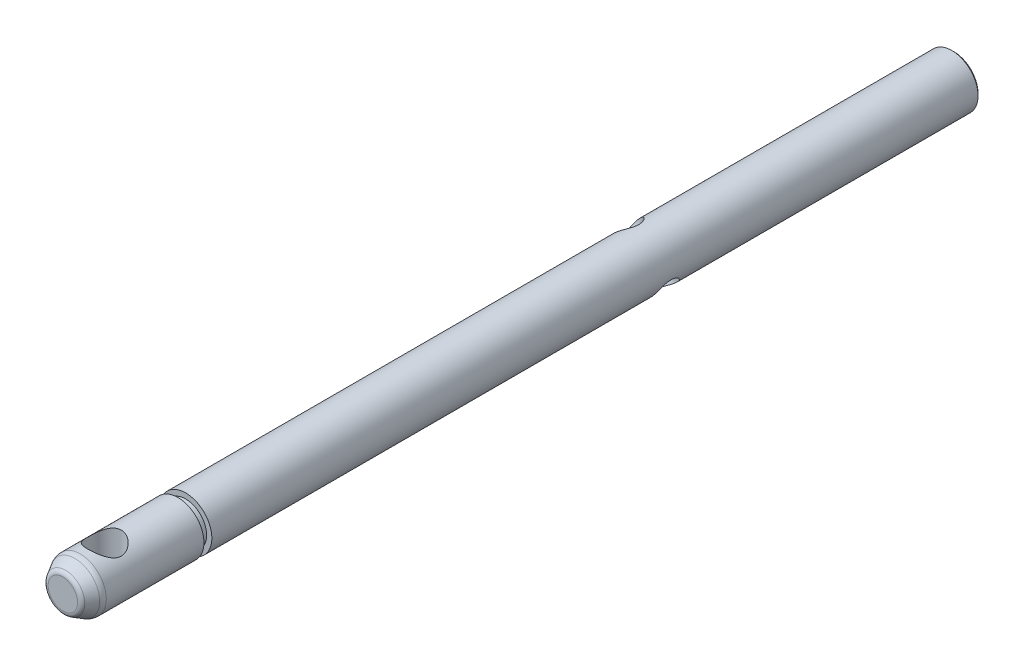
from build123d import *

# Parameters (mm, degrees)
F_1_8_0_125_CLEARANCE_DOWEL_HOLE1_D = 3.175
M3X0_5_TAPPED_HOLE2_D               = 2.5
M3X0_5_TAPPED_HOLE3_D               = 2.5
M3X0_5_TAPPED_HOLE3_DEPTH           = 7.5
M3X0_5_TAPPED_HOLE3_CSINK_D         = 3
M3X0_5_TAPPED_HOLE3_CSINK_ANGLE     = 90
M3X0_5_TAPPED_HOLE3_TIP             = 0.751075774
CHAMFER1_SIZE                       = 0.2
FILLET1_R                           = 1
FILLET2_R                           = 0.5


with BuildPart() as part:
    # Sketch1 → Revolve1 (revolve)
    with BuildSketch(Plane.XZ):
        Polygon((1.7, 11.75), (0, 11.75), (0, -73.5), (2.5, -73.5), (2.5, 0), (2, 0), (2, 0.75), (2.5, 0.75), (2.5, 10.364359355), align=None)
    revolve(axis=Axis((0, 0, 11.75), (0, 0, -1)))

    # 1/8 (0.125) Clearance Dowel Hole1 (through all)
    with Locations(Plane(origin=(0, -2.5, 7.75), x_dir=(-1, 0, 0), z_dir=(0, -1, 0))):
        with Locations((0, 0)):
            Hole(F_1_8_0_125_CLEARANCE_DOWEL_HOLE1_D / 2)

    # M3x0.5 Tapped Hole2 (through all)
    with Locations(Plane(origin=(-1.767766953, 1.767766953, -44), x_dir=(0.707106781, 0.707106781, 0), z_dir=(-0.707106781, 0.707106781, 0))):
        with Locations((0, 0)):
            Hole(M3X0_5_TAPPED_HOLE2_D / 2)

    # M3x0.5 Tapped Hole3
    with Locations(Plane(origin=(0, 0, -73.5), x_dir=(-1, 0, 0), z_dir=(0, 0, -1))):
        with Locations((0, 0)):
            CounterSinkHole(M3X0_5_TAPPED_HOLE3_D / 2, M3X0_5_TAPPED_HOLE3_CSINK_D / 2, depth=M3X0_5_TAPPED_HOLE3_DEPTH, counter_sink_angle=M3X0_5_TAPPED_HOLE3_CSINK_ANGLE)
            with Locations((0, 0, -(M3X0_5_TAPPED_HOLE3_DEPTH + M3X0_5_TAPPED_HOLE3_TIP / 2))):  # 118° drill point
                Cone(0, M3X0_5_TAPPED_HOLE3_D / 2, M3X0_5_TAPPED_HOLE3_TIP, mode=Mode.SUBTRACT)

    # Chamfer1
    chamfer1_edges = [part.edges().sort_by_distance(p)[0] for p in [
        (-2.5, 0, -73.5),
    ]]
    chamfer(chamfer1_edges, length=CHAMFER1_SIZE)

    # Fillet1
    fillet1_edges = [part.edges().sort_by_distance(p)[0] for p in [
        (-2.5, 0, 10.364359355),
    ]]
    fillet(fillet1_edges, radius=FILLET1_R)

    # Fillet2
    fillet2_edges = [part.edges().sort_by_distance(p)[0] for p in [
        (-1.7, 0, 11.75),
    ]]
    fillet(fillet2_edges, radius=FILLET2_R)


solid = part.part
